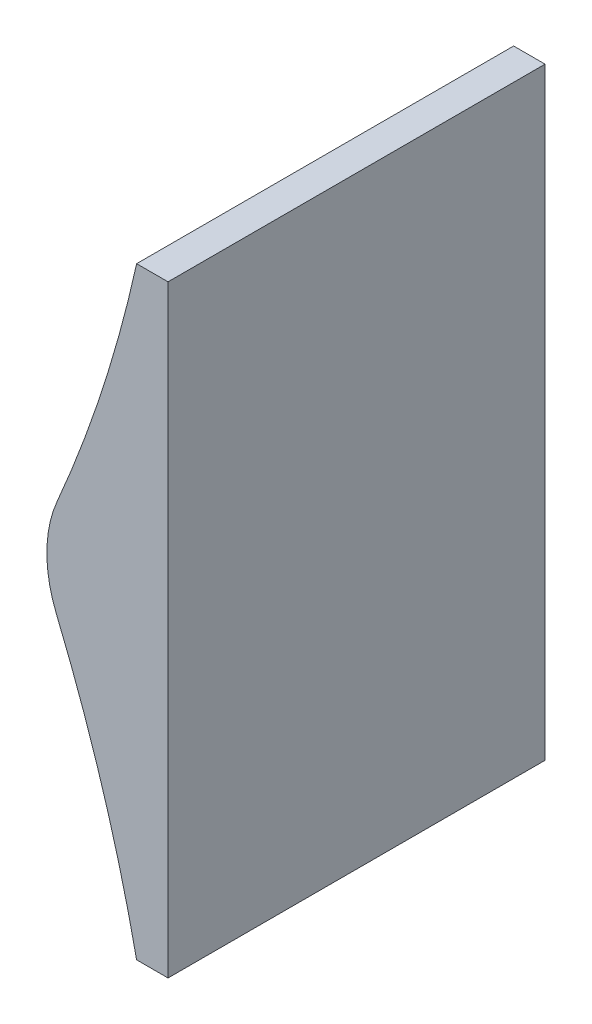
from build123d import *

# Parameters (mm, degrees)
BOSS_EXTRUDE1_DEPTH = 38.1


with BuildPart() as part:
    # Sketch1 → Boss-Extrude1 (new body, symmetric)
    with BuildSketch(Plane.XY):
        with BuildLine():
            Line((487.3625, 481.378335213), (487.3625, 359.522344396))
            Line((487.3625, 359.522344396), (481.0125, 359.522344396))
            ThreePointArc((481.0125, 359.522344396), (474.121977685, 386.119365688), (464.802007403, 411.965429089))
            ThreePointArc((464.802007403, 411.965429089), (462.872580153, 421.889683903), (464.967167576, 431.780398065))
            ThreePointArc((464.967167576, 431.780398065), (474.183122715, 456.193328053), (481.0125, 481.378335213))
            Line((481.0125, 481.378335213), (487.3625, 481.378335213))
        make_face()
    extrude(amount=BOSS_EXTRUDE1_DEPTH, both=True)


solid = part.part
